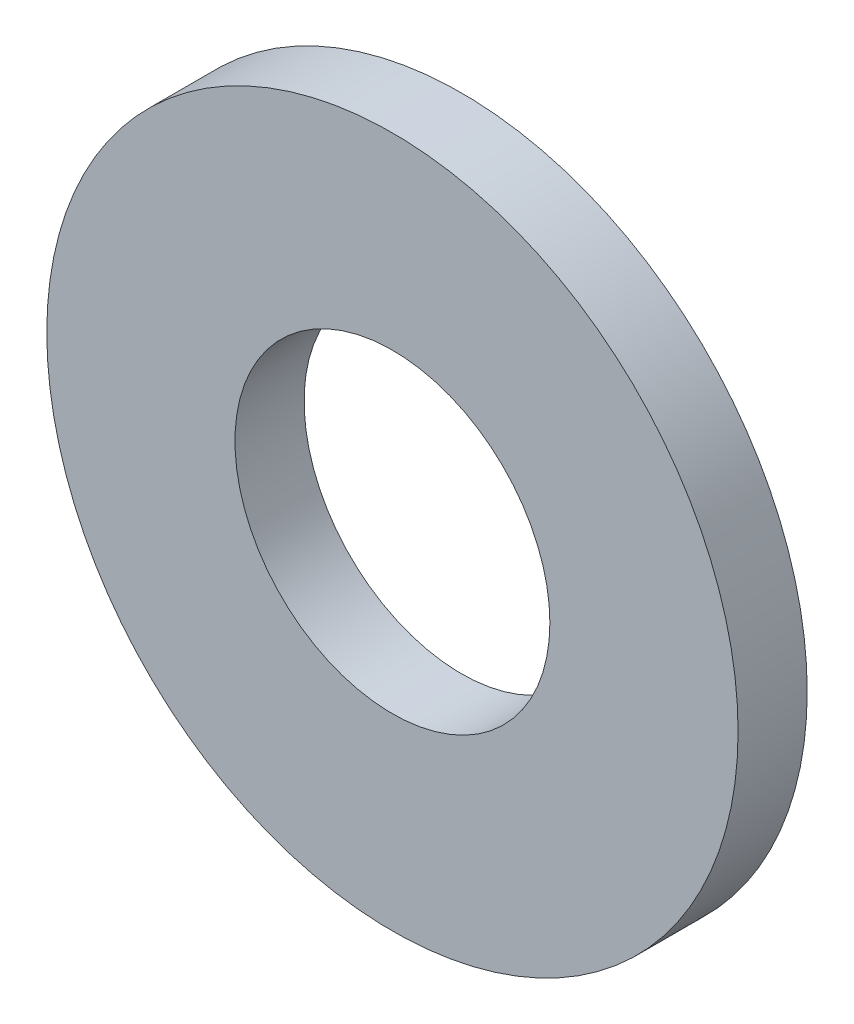
from build123d import *

# Parameters (mm, degrees)
ESBO_O1_R                = 4.5
ESBO_O1_R_2              = 2.05
RESSALTO_EXTRUS_O1_DEPTH = 0.9


with BuildPart() as part:
    # Esboço1 → Ressalto-extrusão1 (new body)
    with BuildSketch(Plane.XY):
        Circle(ESBO_O1_R)
        Circle(ESBO_O1_R_2, mode=Mode.SUBTRACT)
    extrude(amount=RESSALTO_EXTRUS_O1_DEPTH)


solid = part.part
